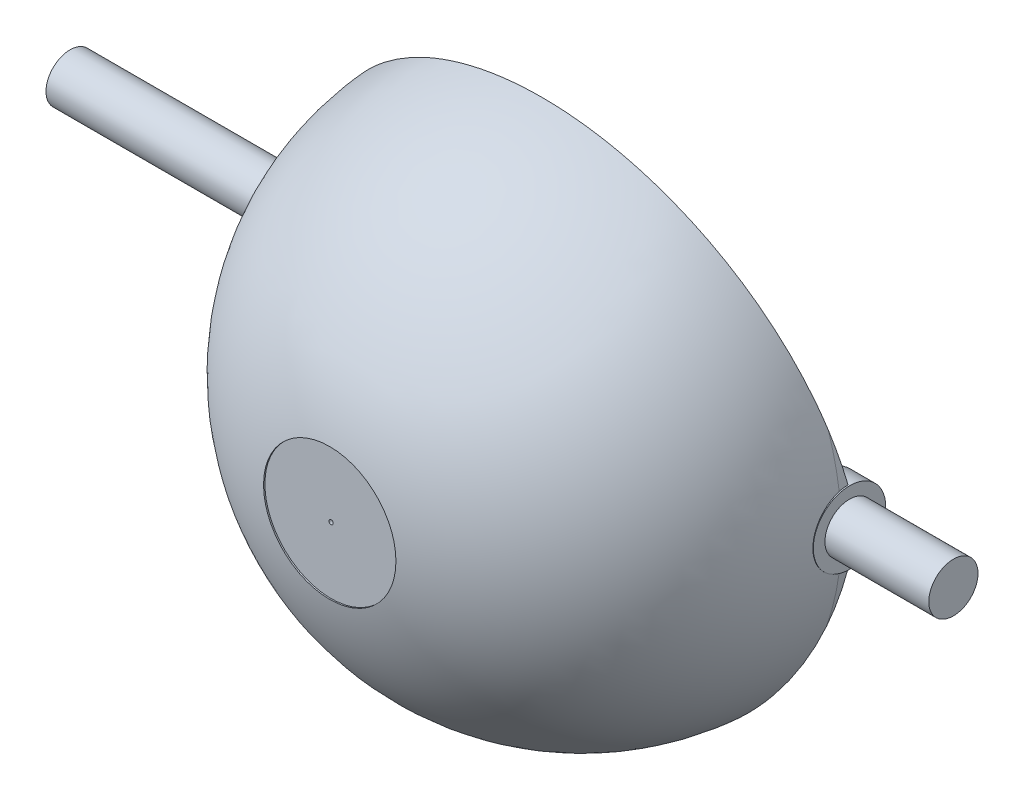
from build123d import *
from build123d.topology import SkipClean

# Parameters (mm, degrees)
SKETCH1_R                = 27.950000405
BOSS_EXTRUDE1_DEPTH      = 27.620221436
FILLET1_R                = 26.67
SHELL1_T                 = -1.778
SKETCH3_W                = 2.977781537
SKETCH3_H                = 2.754447922
BOSS_EXTRUDE3_DEPTH      = 1.016
SKETCH4_R                = 3.820330599
BOSS_EXTRUDE4_DEPTH      = 10.288651178
BOSS_EXTRUDE4_DEPTH_BACK = 82.910790355
SKETCH5_R                = 0.218500346
CUT_EXTRUDE1_DEPTH       = 74.422
SKETCH6_R                = 4.452679147
SKETCH6_R_2              = 2.541856533
CUT_EXTRUDE2_DEPTH       = 26.465589921
SKETCH7_R                = 4.579796813
SKETCH7_R_2              = 2.595326306
CUT_EXTRUDE3_DEPTH       = 10.959776966
SKETCH9_R                = 25.327508304
CUT_EXTRUDE4_DEPTH       = 8.128
CUT_EXTRUDE4_DEPTH_BACK  = 4.572
SKETCH10_R               = 0.226571895
CUT_EXTRUDE5_DEPTH       = 5.588
SKETCH11_R               = 0.957654217
BOSS_EXTRUDE5_DEPTH      = 22.86
SKETCH12_R               = 3.048
BOSS_EXTRUDE6_DEPTH      = 10.78430752
BOSS_EXTRUDE6_2_DEPTH    = 10.78430752
SKETCH14_R               = 2.111885876
CUT_EXTRUDE6_DEPTH       = 33.274
CUT_EXTRUDE7_DEPTH       = 66.802
CUT_EXTRUDE8_DEPTH       = 66.802
SKETCH17_R               = 6.985
CUT_EXTRUDE9_DEPTH       = 0.762
BOSS_EXTRUDE7_DEPTH      = 3.302
BOSS_EXTRUDE8_DEPTH      = 4.572


with BuildPart() as part:
    # Sketch1 → Boss-Extrude1 (new body)
    with BuildSketch(Plane.XY):
        Circle(SKETCH1_R)
    extrude(amount=BOSS_EXTRUDE1_DEPTH)

    # Fillet1
    fillet1_edges = [part.edges().sort_by_distance(p)[0] for p in [
        (-27.950000405, 0, 27.620221436),
    ]]
    fillet(fillet1_edges, radius=FILLET1_R)

    # Shell1
    shell1_openings = [part.faces().sort_by_distance(p)[0] for p in [
        (0, 0, 0),
    ]]
    offset(amount=SHELL1_T, openings=shell1_openings, kind=Kind.INTERSECTION)

    # Sketch3 → Boss-Extrude3 (add)
    with BuildSketch(Plane(origin=(0, 0, 0), x_dir=(-1, 0, 0), z_dir=(0, 0, -1))):
        with Locations((-27.023367447, 0)):
            Rectangle(SKETCH3_W, SKETCH3_H)
    extrude(amount=BOSS_EXTRUDE3_DEPTH)

    # Sketch4 → Boss-Extrude4 (add, two sides)
    with BuildSketch(Plane(origin=(28.512258215, 0, 0), x_dir=(0, 0, -1), z_dir=(1, 0, 0))) as boss_extrude4_sk:
        Circle(SKETCH4_R)
    extrude(amount=BOSS_EXTRUDE4_DEPTH)
    extrude(boss_extrude4_sk.sketch, amount=-BOSS_EXTRUDE4_DEPTH_BACK)

    # Sketch5 → Cut-Extrude1 (cut)
    with BuildSketch(Plane.ZY.offset(54.39853214)):
        Circle(SKETCH5_R)
    extrude(amount=-CUT_EXTRUDE1_DEPTH, mode=Mode.SUBTRACT)

    # Sketch6 → Cut-Extrude2 (cut)
    with BuildSketch(Plane.ZY.offset(54.39853214)):
        Circle(SKETCH6_R)
        Circle(SKETCH6_R_2, mode=Mode.SUBTRACT)
    extrude(amount=-CUT_EXTRUDE2_DEPTH, mode=Mode.SUBTRACT)

    # Sketch7 → Cut-Extrude3 (cut)
    with BuildSketch(Plane(origin=(38.800909393, 0, 0), x_dir=(0, 0, -1), z_dir=(1, 0, 0))):
        Circle(SKETCH7_R)
        Circle(SKETCH7_R_2, mode=Mode.SUBTRACT)
    extrude(amount=-CUT_EXTRUDE3_DEPTH, mode=Mode.SUBTRACT)

    # Sketch9 → Cut-Extrude4 (cut, two sides)
    with BuildSketch(Plane(origin=(0, 0, 0), x_dir=(-1, 0, 0), z_dir=(0, 0, -1))) as cut_extrude4_sk:
        Circle(SKETCH9_R)
    extrude(amount=CUT_EXTRUDE4_DEPTH, mode=Mode.SUBTRACT)
    extrude(cut_extrude4_sk.sketch, amount=-CUT_EXTRUDE4_DEPTH_BACK, mode=Mode.SUBTRACT)

    # Sketch10 → Cut-Extrude5 (cut)
    with BuildSketch(Plane.XY.offset(27.620221436)):
        Circle(SKETCH10_R)
    extrude(amount=-CUT_EXTRUDE5_DEPTH, mode=Mode.SUBTRACT)

    # Sketch15 → Cut-Extrude7 (cut)
    with BuildSketch(Plane(origin=(38.800909393, 0, 0), x_dir=(0, 0, -1), z_dir=(1, 0, 0))):
        Polygon((0, 3.820330599), (-4.891274508, 29.145036791), (1.659844873, 29.145036791), align=None)
    extrude(amount=-CUT_EXTRUDE7_DEPTH, mode=Mode.SUBTRACT)

    # Sketch16 → Cut-Extrude8 (cut)
    with BuildSketch(Plane(origin=(38.800909393, 0, 0), x_dir=(0, 0, -1), z_dir=(1, 0, 0))):
        Polygon((0, -3.820330599), (-4.28892383, -28.486260213), (3.820330599, -28.486260213), align=None)
    extrude(amount=-CUT_EXTRUDE8_DEPTH, mode=Mode.SUBTRACT)

    # Sketch17 → Cut-Extrude9 (cut)
    with BuildSketch(Plane.XY.offset(27.620221436)):
        Circle(SKETCH17_R)
    extrude(amount=-CUT_EXTRUDE9_DEPTH, mode=Mode.SUBTRACT)



with BuildPart() as body_2:
    # Sketch11 → Boss-Extrude5 (new body)
    with BuildSketch(Plane.XY.offset(27.599408823)):
        Circle(SKETCH11_R)
    extrude(amount=-BOSS_EXTRUDE5_DEPTH)

    # Sketch14 → Cut-Extrude6 (cut)
    with BuildSketch(Plane(origin=(0, 0, 0), x_dir=(-1, 0, 0), z_dir=(0, 0, -1))):
        Circle(SKETCH14_R)
    extrude(amount=-CUT_EXTRUDE6_DEPTH, mode=Mode.SUBTRACT)


with BuildPart() as body_3:
    # Sketch12 → Boss-Extrude6 (new body)
    with BuildSketch(Plane(origin=(0, 0, 4.739408823), x_dir=(-1, 0, 0), z_dir=(0, 0, -1))):
        with Locations((11.938, 16.638354337)):
            Circle(SKETCH12_R)
    extrude(amount=-BOSS_EXTRUDE6_DEPTH)


with BuildPart() as body_4:
    # Sketch12 → Boss-Extrude6 2 (new body)
    with BuildSketch(Plane(origin=(0, 0, 4.739408823), x_dir=(-1, 0, 0), z_dir=(0, 0, -1))):
        with Locations((-11.953495285, -16.638354337)):
            Circle(SKETCH12_R)
    extrude(amount=-BOSS_EXTRUDE6_2_DEPTH)


with BuildPart() as part_1:
    add(part.part)

    add(body_3.part)  # Boss-Extrude7 merges body 3
    # Sketch18 → Boss-Extrude7 (add)
    with BuildSketch(Plane(origin=(0, 0, 4.739408823), x_dir=(-1, 0, 0), z_dir=(0, 0, -1))):
        Polygon((9.396577434, 18.321053164), (12.856272932, 23.546318713), (17.452915624, 20.502840084), (14.479422566, 14.95565551), align=None)
    extrude(amount=-BOSS_EXTRUDE7_DEPTH)


    with SkipClean():  # the faces are left unmerged after this step: merging them gives an invalid solid
        add(body_4.part)  # Boss-Extrude8 merges body 4
        # Sketch19 → Boss-Extrude8 (add)
        with BuildSketch(Plane(origin=(0, 0, 4.739408823), x_dir=(-1, 0, 0), z_dir=(0, 0, -1))):
            Polygon((-14.498283748, -14.960750189), (-17.613549805, -19.686354337), (-12.938248054, -22.625591837), (-9.601439985, -18.576946575), align=None)
        extrude(amount=-BOSS_EXTRUDE8_DEPTH)


solid = part_1.part
